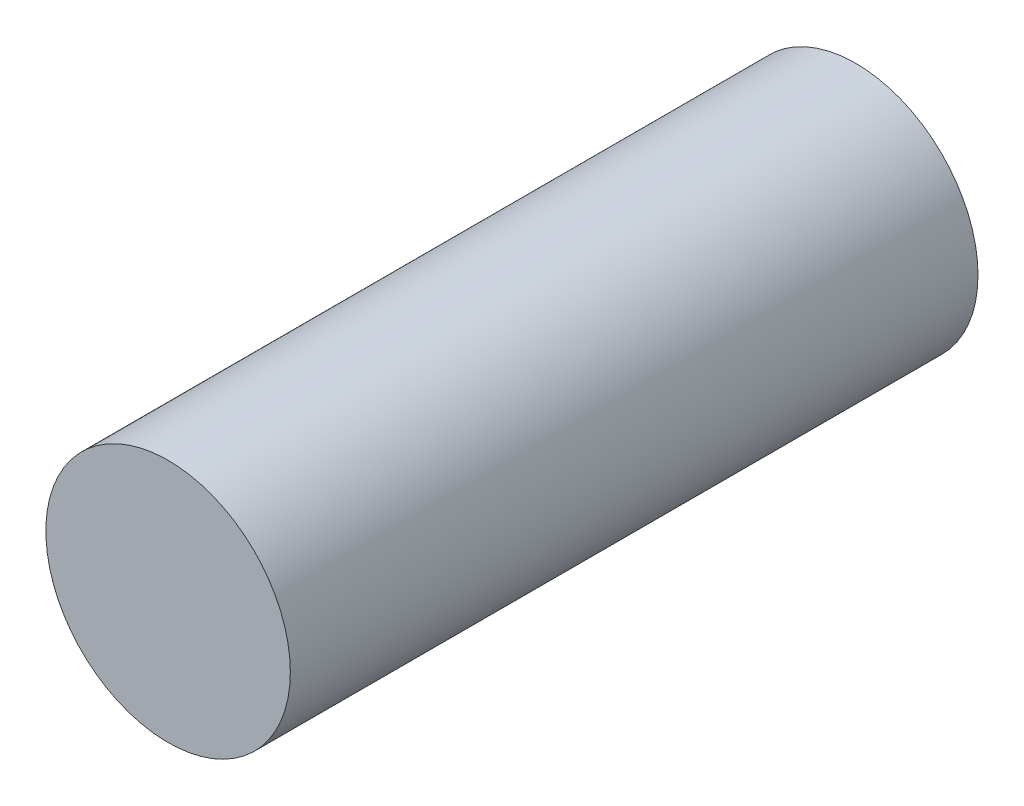
from build123d import *

# Parameters (mm, degrees)
SKETCH1_R      = 1600
EXTRUDE1_DEPTH = 9000


with BuildPart() as part:
    # Sketch1 → Extrude1 (new body)
    with BuildSketch(Plane.XY):
        with Locations((25169.543993222, 38791.520325868)):
            Circle(SKETCH1_R)
    extrude(amount=EXTRUDE1_DEPTH)


solid = part.part
